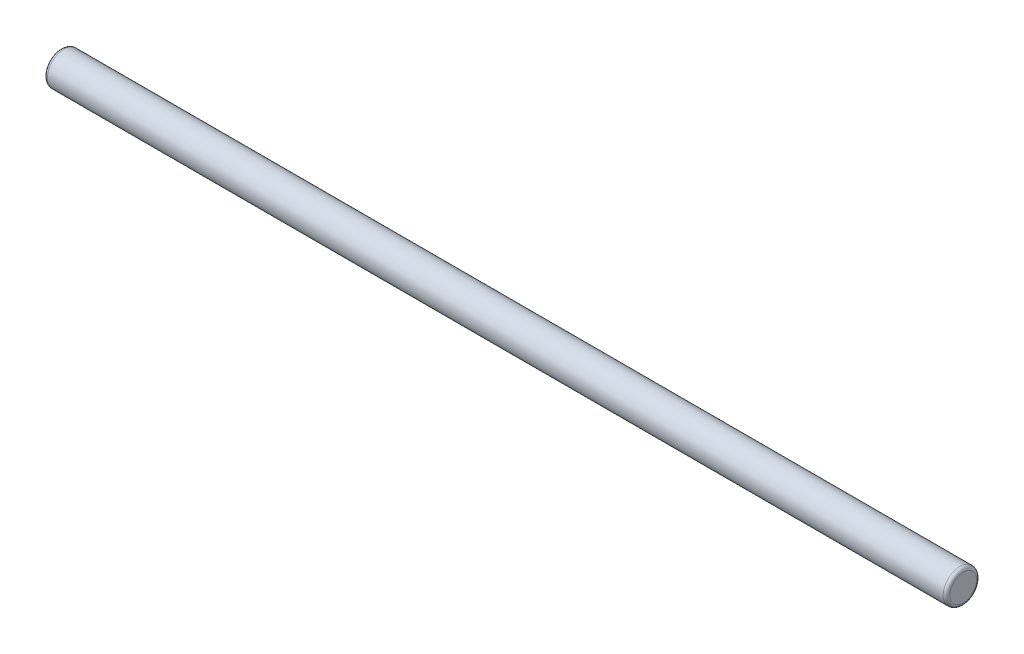
from build123d import *

# Parameters (mm, degrees)
SKETCH1_R           = 5
BOSS_EXTRUDE1_DEPTH = 270
FILLET1_R           = 1


with BuildPart() as part:
    # Sketch1 → Boss-Extrude1 (new body)
    with BuildSketch(Plane(origin=(0, 0, 0), x_dir=(0, 0, -1), z_dir=(1, 0, 0))):
        Circle(SKETCH1_R)
    extrude(amount=BOSS_EXTRUDE1_DEPTH)

    # Fillet1
    fillet1_edges = [part.edges().sort_by_distance(p)[0] for p in [
        (0, 0, 5),
        (270, 0, 5),
    ]]
    fillet(fillet1_edges, radius=FILLET1_R)


solid = part.part
